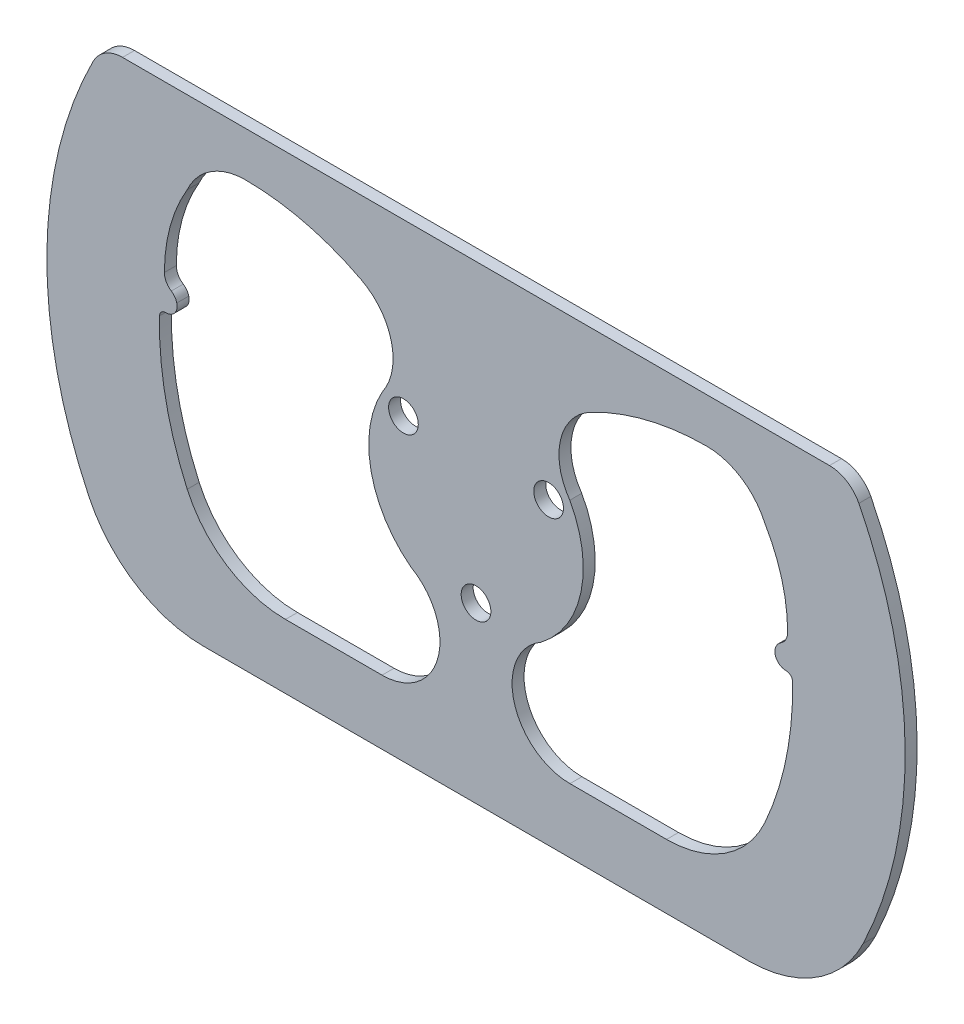
from build123d import *

# Parameters (mm, degrees)
SKETCH1_R           = 3.937
BOSS_EXTRUDE1_DEPTH = 3.175


with BuildPart() as part:
    # Sketch1 → Boss-Extrude1 (new body)
    with BuildSketch(Plane.XY):
        with BuildLine():
            Line((93.755372783, 56.217862378), (-93.755372783, 56.217862378))
            ThreePointArc((-93.755372783, 56.217862378), (-98.330168366, 54.924590712), (-101.550779975, 51.427596704))
            ThreePointArc((-101.550779975, 51.427596704), (-113.823339918, 1.267243548), (-102.670596612, -49.153913451))
            ThreePointArc((-102.670596612, -49.153913451), (-90.230339267, -63.122833424), (-72.258999564, -68.311443769))
            Line((-72.258999564, -68.311443769), (72.258999564, -68.311443769))
            ThreePointArc((72.258999564, -68.311443769), (90.230339267, -63.122833424), (102.670596612, -49.153913451))
            ThreePointArc((102.670596612, -49.153913451), (113.823339918, 1.267243548), (101.550779975, 51.427596704))
            ThreePointArc((101.550779975, 51.427596704), (98.330168366, 54.924590712), (93.755372783, 56.217862378))
        make_face()
        with Locations((0, -22.231680406)):
            Circle(SKETCH1_R, mode=Mode.SUBTRACT)
        with Locations((-19.2532, 11.115840203)):
            Circle(SKETCH1_R, mode=Mode.SUBTRACT)
        with Locations((19.2532, 11.115840203)):
            Circle(SKETCH1_R, mode=Mode.SUBTRACT)
        with BuildLine():
            Line((50.537610963, -51.271802519), (24.921430241, -51.271802519))
            ThreePointArc((24.921430241, -51.271802519), (10.088644213, -39.88245969), (17.262248757, -22.612020516))
            ThreePointArc((17.262248757, -22.612020516), (27.847341492, -5.815004372), (24.868702617, 13.81435247))
            ThreePointArc((24.868702617, 13.81435247), (22.438574631, 26.570482702), (30.438512771, 36.799137076))
            ThreePointArc((30.438512771, 36.799137076), (45.320271887, 42.430959459), (61.111403686, 44.386549975))
            ThreePointArc((61.111403686, 44.386549975), (70.335617903, 41.69195489), (76.601720977, 34.406152063))
            ThreePointArc((76.601720977, 34.406152063), (81.115925355, 23.793617751), (82.657376867, 12.364363491))
            ThreePointArc((82.657376867, 12.364363491), (82.169800307, 10.456907156), (80.826687149, 9.017404598))
            ThreePointArc((80.826687149, 9.017404598), (79.903262527, 8.142769936), (79.366676242, 6.98961167))
            ThreePointArc((79.366676242, 6.98961167), (79.918421039, 4.432989113), (82.285769804, 3.321053391))
            ThreePointArc((82.285769804, 3.321053391), (83.453127799, 2.865261142), (83.956280763, 1.717520598))
            ThreePointArc((83.956280763, 1.717520598), (82.285769804, -16.752881668), (76.601720977, -34.406152063))
            ThreePointArc((76.601720977, -34.406152063), (66.06007852, -46.687651069), (50.537610963, -51.271802519))
        make_face(mode=Mode.SUBTRACT)
        with BuildLine():
            Line((-50.537610963, -51.271802519), (-24.921430241, -51.271802519))
            ThreePointArc((-24.921430241, -51.271802519), (-10.088644213, -39.88245969), (-17.262248757, -22.612020516))
            ThreePointArc((-17.262248757, -22.612020516), (-27.847341492, -5.815004372), (-24.868702617, 13.81435247))
            ThreePointArc((-24.868702617, 13.81435247), (-22.438574631, 26.570482702), (-30.438512771, 36.799137076))
            ThreePointArc((-30.438512771, 36.799137076), (-45.320271887, 42.430959459), (-61.111403686, 44.386549975))
            ThreePointArc((-61.111403686, 44.386549975), (-70.335617903, 41.69195489), (-76.601720977, 34.406152063))
            ThreePointArc((-76.601720977, 34.406152063), (-81.115925355, 23.793617751), (-82.657376867, 12.364363491))
            ThreePointArc((-82.657376867, 12.364363491), (-82.169800307, 10.456907156), (-80.826687149, 9.017404598))
            ThreePointArc((-80.826687149, 9.017404598), (-79.903262527, 8.142769936), (-79.366676242, 6.98961167))
            ThreePointArc((-79.366676242, 6.98961167), (-79.918421039, 4.432989113), (-82.285769804, 3.321053391))
            ThreePointArc((-82.285769804, 3.321053391), (-83.453127799, 2.865261142), (-83.956280763, 1.717520598))
            ThreePointArc((-83.956280763, 1.717520598), (-82.285769804, -16.752881668), (-76.601720977, -34.406152063))
            ThreePointArc((-76.601720977, -34.406152063), (-66.06007852, -46.687651069), (-50.537610963, -51.271802519))
        make_face(mode=Mode.SUBTRACT)
    extrude(amount=BOSS_EXTRUDE1_DEPTH)


solid = part.part
